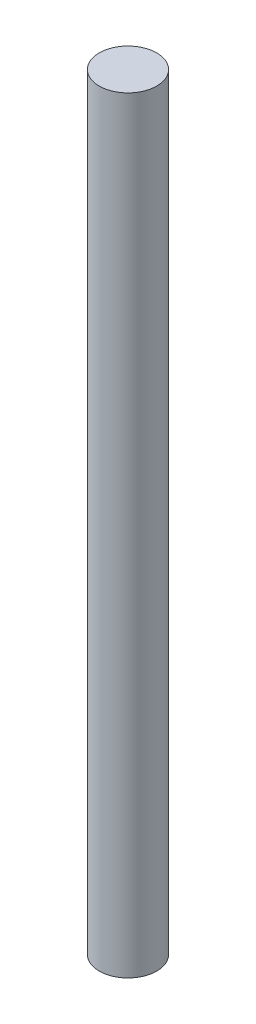
from build123d import *

# Parameters (mm, degrees)
SKETCH1_R           = 0.75
BOSS_EXTRUDE1_DEPTH = 20


with BuildPart() as part:
    # Sketch1 → Boss-Extrude1 (new body)
    with BuildSketch(Plane(origin=(0, 0, 0), x_dir=(1, 0, 0), z_dir=(0, 1, 0))):
        Circle(SKETCH1_R)
    extrude(amount=BOSS_EXTRUDE1_DEPTH)


solid = part.part
